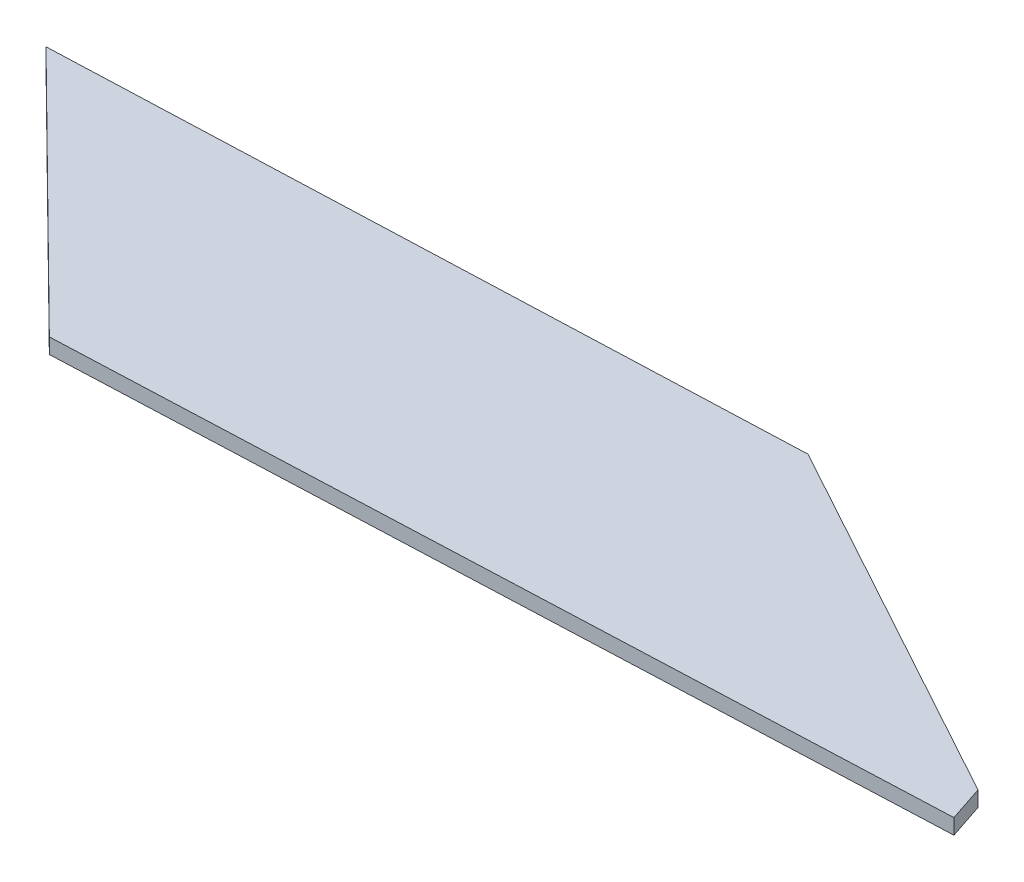
from build123d import *

# Parameters (mm, degrees)
BOSS_EXTRU_1_DEPTH = 2


with BuildPart() as part:
    # Esquisse1 → Boss.-Extru.1 (new body)
    with BuildSketch(Plane(origin=(0, 0, 0), x_dir=(1, 0, 0), z_dir=(0, 1, 0))):
        Polygon((112.175529537, 9.43186764), (62.964600566, 36.378847329), (-33.122068319, 32.684786879), (0, 0), (113.73842941, 4.717500652), align=None)
    extrude(amount=BOSS_EXTRU_1_DEPTH)


solid = part.part
